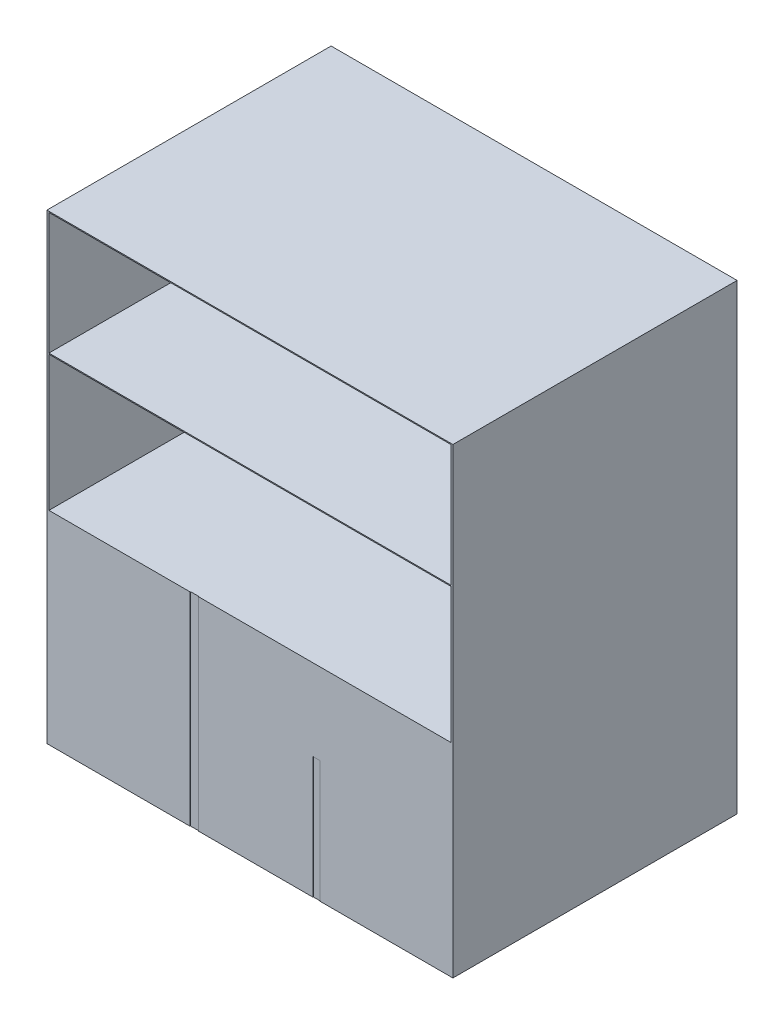
from build123d import *

# Parameters (mm, degrees)
CROQUIS1_W              = 2000
CROQUIS1_H              = 1400
SALIENTE_EXTRUIR1_DEPTH = 1000
CROQUIS2_W              = 40.721486725
CROQUIS2_H              = 1000
CROQUIS2_W_2            = 34.613400616
CROQUIS2_H_2            = 600
CORTAR_EXTRUIR1_DEPTH   = 2
SALIENTE_EXTRUIR2_DEPTH = 666
CROQUIS6_W              = 2000
CROQUIS6_H              = 1400
SALIENTE_EXTRUIR3_DEPTH = 610
CROQUIS7_W              = 1980
CROQUIS7_H              = 600
CORTAR_EXTRUIR4_DEPTH   = 1300


with BuildPart() as part:
    # Croquis1 → Saliente-Extruir1 (new body)
    with BuildSketch(Plane(origin=(0, 0, 0), x_dir=(1, 0, 0), z_dir=(0, 1, 0))):
        Rectangle(CROQUIS1_W, CROQUIS1_H)
    extrude(amount=SALIENTE_EXTRUIR1_DEPTH)

    # Croquis2 → Cortar-Extruir1 (cut)
    with BuildSketch(Plane.XY.offset(700)):
        with Locations((-274.287558023, 500)):
            Rectangle(CROQUIS2_W, CROQUIS2_H)
        with Locations((327.607420408, 300)):
            Rectangle(CROQUIS2_W_2, CROQUIS2_H_2)
    extrude(amount=-CORTAR_EXTRUIR1_DEPTH, mode=Mode.SUBTRACT)

    # Croquis5 → Saliente-Extruir2 (add)
    with BuildSketch(Plane(origin=(0, 1000, 0), x_dir=(1, 0, 0), z_dir=(0, 1, 0))):
        Polygon((1000, -700), (990, -700), (990, -690), (990, 690), (-990, 690), (-990, -690), (-990, -700), (-1000, -700), (-1000, 700), (1000, 700), align=None)
    extrude(amount=SALIENTE_EXTRUIR2_DEPTH)

    # Croquis6 → Saliente-Extruir3 (add)
    with BuildSketch(Plane(origin=(0, 1666, 0), x_dir=(1, 0, 0), z_dir=(0, 1, 0))):
        Rectangle(CROQUIS6_W, CROQUIS6_H)
    extrude(amount=SALIENTE_EXTRUIR3_DEPTH)

    # Croquis7 → Cortar-Extruir4 (cut)
    with BuildSketch(Plane.XY.offset(700)):
        with Locations((0, 1971)):
            Rectangle(CROQUIS7_W, CROQUIS7_H)
    extrude(amount=-CORTAR_EXTRUIR4_DEPTH, mode=Mode.SUBTRACT)


solid = part.part
